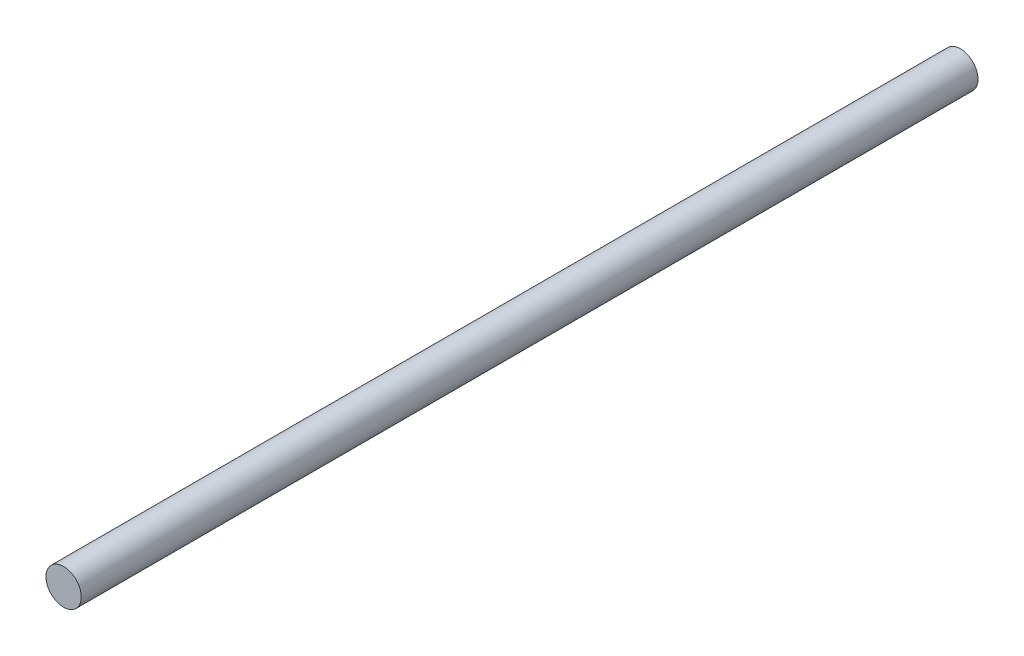
from build123d import *

# Parameters (mm, degrees)
SKETCH1_R           = 2.5
BOSS_EXTRUDE1_DEPTH = 127


with BuildPart() as part:
    # Sketch1 → Boss-Extrude1 (new body)
    with BuildSketch(Plane.XY):
        with Locations((-0.914484114, 1.273567416)):
            Circle(SKETCH1_R)
    extrude(amount=BOSS_EXTRUDE1_DEPTH)


solid = part.part
